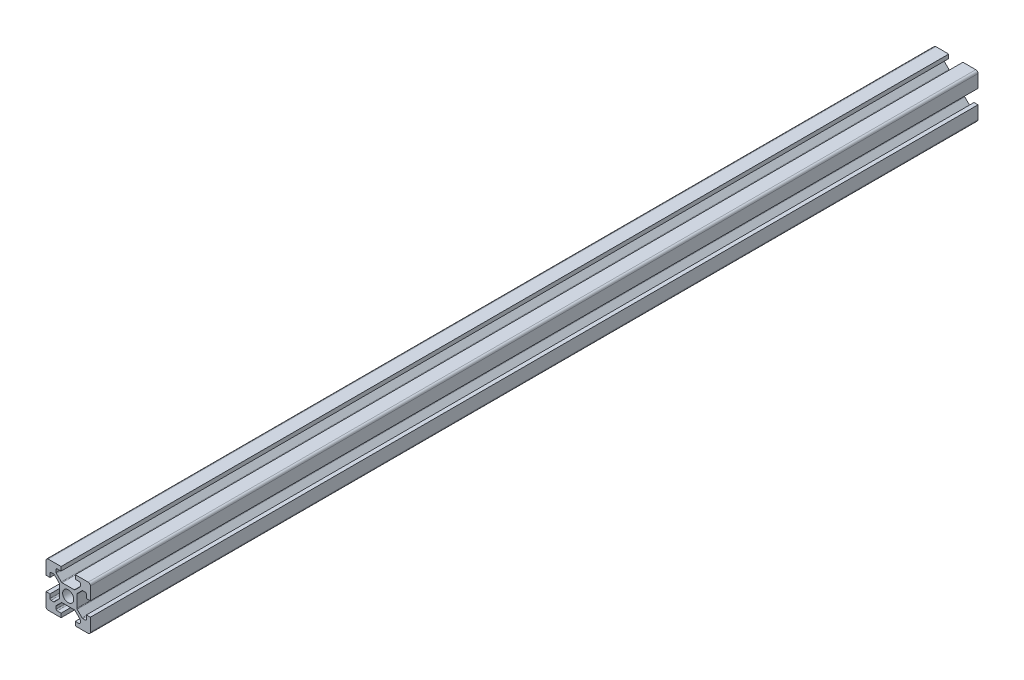
from build123d import *

# Parameters (mm, degrees)
SKETCH1_R           = 2.5
BOSS_EXTRUDE1_DEPTH = 400
FILLET1_R           = 1
FILLET2_R           = 0.5
FILLET3_R           = 0.5
FILLET4_R           = 0.5
FILLET5_R           = 0.5


with BuildPart() as part:
    # Sketch1 → Boss-Extrude1 (new body)
    with BuildSketch(Plane.XY):
        Polygon((13.2, 0), (13.2, 1.8), (15.45, 1.8), (15.45, 3.6), (12.95, 6.1), (7.05, 6.1), (4.55, 3.6), (4.55, 1.8), (6.8, 1.8), (6.8, 0), (0, 0), (0, 6.8), (1.8, 6.8), (1.8, 4.55), (3.6, 4.55), (6.1, 7.05), (6.1, 12.95), (3.6, 15.45), (1.8, 15.45), (1.8, 13.2), (0, 13.2), (0, 20), (6.8, 20), (6.8, 18.2), (4.55, 18.2), (4.55, 16.4), (7.05, 13.9), (12.95, 13.9), (15.45, 16.4), (15.45, 18.2), (13.2, 18.2), (13.2, 20), (20, 20), (20, 13.2), (18.2, 13.2), (18.2, 15.45), (16.4, 15.45), (13.9, 12.95), (13.9, 7.05), (16.4, 4.55), (18.2, 4.55), (18.2, 6.8), (20, 6.8), (20, 0), align=None)
        with Locations((10, 10)):
            Circle(SKETCH1_R, mode=Mode.SUBTRACT)
    extrude(amount=BOSS_EXTRUDE1_DEPTH)

    # Fillet1
    fillet1_edges = [part.edges().sort_by_distance(p)[0] for p in [
        (0, 0, 200),
        (0, 20, 200),
        (20, 20, 200),
        (20, 0, 200),
    ]]
    fillet(fillet1_edges, radius=FILLET1_R)

    # Fillet2
    fillet2_edges = [part.edges().sort_by_distance(p)[0] for p in [
        (4.55, 18.2, 200),
        (4.55, 16.4, 200),
        (7.05, 13.9, 200),
        (12.95, 13.9, 200),
        (15.45, 16.4, 200),
        (15.45, 18.2, 200),
    ]]
    fillet(fillet2_edges, radius=FILLET2_R)

    # Fillet3
    fillet3_edges = [part.edges().sort_by_distance(p)[0] for p in [
        (18.2, 15.45, 200),
        (16.4, 15.45, 200),
        (13.9, 12.95, 200),
        (13.9, 7.05, 200),
        (16.4, 4.55, 200),
        (18.2, 4.55, 200),
    ]]
    fillet(fillet3_edges, radius=FILLET3_R)

    # Fillet4
    fillet4_edges = [part.edges().sort_by_distance(p)[0] for p in [
        (1.8, 4.55, 200),
        (3.6, 4.55, 200),
        (6.1, 7.05, 200),
        (6.1, 12.95, 200),
        (3.6, 15.45, 200),
        (1.8, 15.45, 200),
    ]]
    fillet(fillet4_edges, radius=FILLET4_R)

    # Fillet5
    fillet5_edges = [part.edges().sort_by_distance(p)[0] for p in [
        (15.45, 1.8, 200),
        (15.45, 3.6, 200),
        (12.95, 6.1, 200),
        (7.05, 6.1, 200),
        (4.55, 3.6, 200),
        (4.55, 1.8, 200),
    ]]
    fillet(fillet5_edges, radius=FILLET5_R)


solid = part.part
